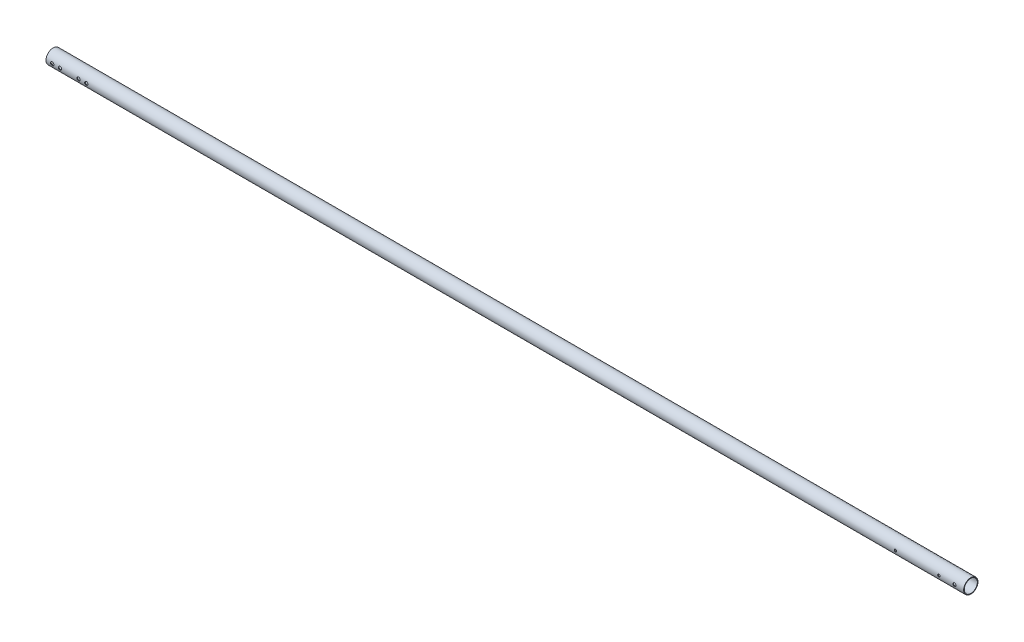
from build123d import *

# Parameters (mm, degrees)
SKETCH1_R               = 14.732
SKETCH1_R_2             = 13.3858
BOSS_EXTRUDE1_DEPTH     = 1881.1875
SKETCH2_R               = 2.4638
SKETCH2_R_2             = 3.175
CUT_EXTRUDE2_DEPTH      = 15.732
CUT_EXTRUDE2_DEPTH_BACK = 15.732
SKETCH3_R               = 3.3655
CUT_EXTRUDE3_DEPTH      = 15.7320001
LPATTERN1_COUNT         = 2
LPATTERN1_PITCH         = 53.975


with BuildPart() as part:
    # Sketch1 → Boss-Extrude1 (new body)
    with BuildSketch(Plane(origin=(0, 0, 0), x_dir=(0, 0, -1), z_dir=(1, 0, 0))):
        Circle(SKETCH1_R)
        Circle(SKETCH1_R_2, mode=Mode.SUBTRACT)
    extrude(amount=BOSS_EXTRUDE1_DEPTH)

    # Sketch2 → Cut-Extrude2 (cut, two sides)
    with BuildSketch(Plane.XY) as cut_extrude2_sk:
        with Locations((1830.3875, 0)):
            Circle(SKETCH2_R)
        with Locations((1741.4875, 0)):
            Circle(SKETCH2_R)
        with Locations((1862.1375, 0)):
            Circle(SKETCH2_R_2)
    extrude(amount=CUT_EXTRUDE2_DEPTH, mode=Mode.SUBTRACT)
    extrude(cut_extrude2_sk.sketch, amount=-CUT_EXTRUDE2_DEPTH_BACK, mode=Mode.SUBTRACT)

    # Sketch3 → Cut-Extrude3 (cut, symmetric)
    with BuildSketch(Plane.XY):
        with Locations((12.7, 0)):
            Circle(SKETCH3_R)
        with Locations((28.575, 0)):
            Circle(SKETCH3_R)
    cut_extrude3 = extrude(amount=CUT_EXTRUDE3_DEPTH, both=True, mode=Mode.SUBTRACT)

    # LPattern1: Cut-Extrude3 ×2
    with Locations(*[(i * LPATTERN1_PITCH, 0, 0) for i in range(1, LPATTERN1_COUNT)]):
        add(cut_extrude3, mode=Mode.SUBTRACT)


solid = part.part
